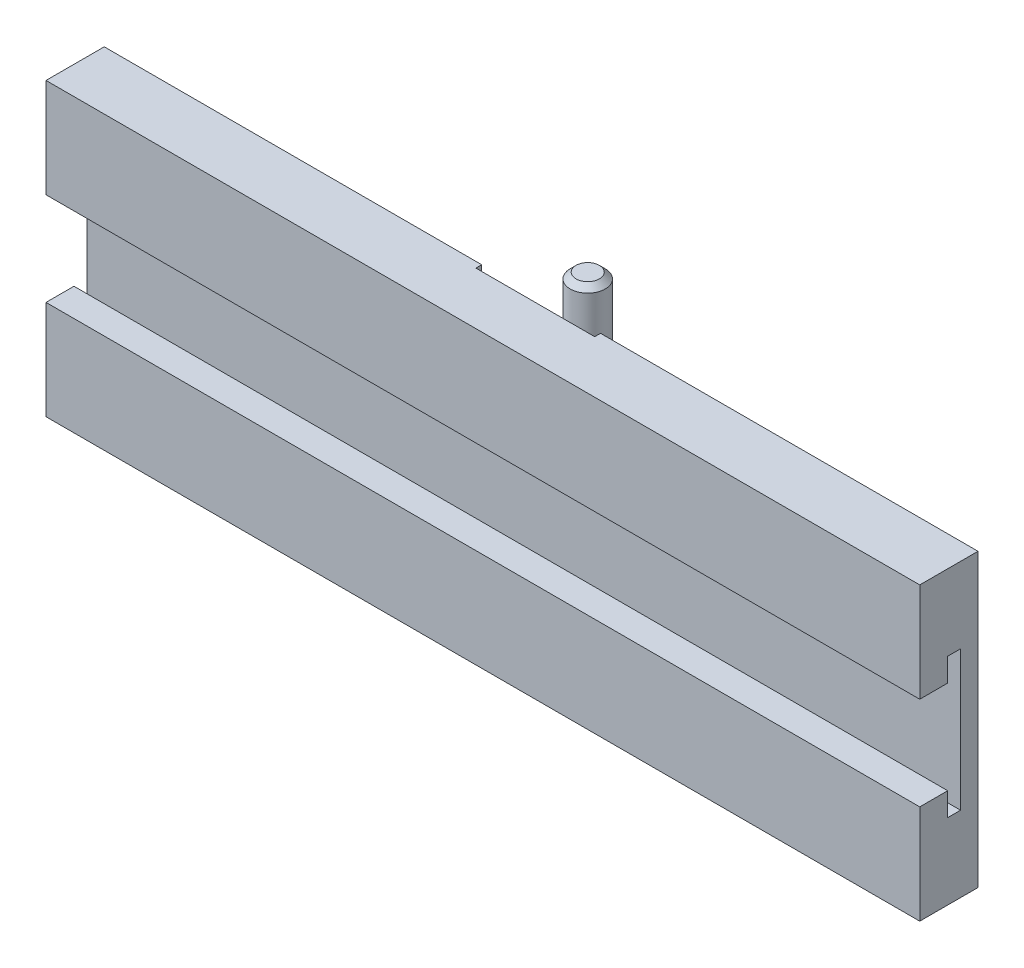
from build123d import *

# Parameters (mm, degrees)
SKETCH_1_W          = 150
SKETCH_1_H          = 50
EXTRUDE_1_DEPTH     = 10
CUT_EXTRUDE_1_DEPTH = 150
SKETCH_3_W          = 20.4
SKETCH_3_H          = 1
CUT_EXTRUDE_2_DEPTH = 150
SKETCH_4_W          = 20.4
SKETCH_4_H          = 5
EXTRUDE_2_DEPTH     = 12
SKETCH_5_R          = 3.01
EXTRUDE_3_DEPTH     = 45
CHAMFER_2_SIZE      = 1


with BuildPart() as part:
    # 草图1 → 凸台-拉伸1 (new body)
    with BuildSketch(Plane.XY):
        with Locations((50.269431659, 25)):
            Rectangle(SKETCH_1_W, SKETCH_1_H)
    extrude(amount=EXTRUDE_1_DEPTH)

    # 草图2 → 切除-拉伸1 (cut)
    with BuildSketch(Plane(origin=(125.269431659, 0, 0), x_dir=(0, 0, -1), z_dir=(1, 0, 0))):
        Polygon((-3, 13), (-3, 37), (-5.2, 37), (-5.2, 33), (-10, 33), (-10, 17), (-5.2, 17), (-5.2, 13), align=None)
    extrude(amount=-CUT_EXTRUDE_1_DEPTH, mode=Mode.SUBTRACT)

    # 草图3 → 切除-拉伸2 (cut)
    with BuildSketch(Plane(origin=(0, 50, 0), x_dir=(1, 0, 0), z_dir=(0, 1, 0))):
        with Locations((50.269431659, -0.5)):
            Rectangle(SKETCH_3_W, SKETCH_3_H)
    extrude(amount=-CUT_EXTRUDE_2_DEPTH, mode=Mode.SUBTRACT)

    # 草图4 → 凸台-拉伸2 (add)
    with BuildSketch(Plane(origin=(0, 0, 1), x_dir=(-1, 0, 0), z_dir=(0, 0, -1))):
        with Locations((-50.269431659, 2.5)):
            Rectangle(SKETCH_4_W, SKETCH_4_H)
    extrude(amount=EXTRUDE_2_DEPTH)

    # 草图5 → 凸台-拉伸3 (add)
    with BuildSketch(Plane(origin=(0, 5, 0), x_dir=(1, 0, 0), z_dir=(0, 1, 0))):
        with Locations((50.269431659, 8)):
            Circle(SKETCH_5_R)
    extrude(amount=EXTRUDE_3_DEPTH)

    # 倒角2
    chamfer_2_edges = [part.edges().sort_by_distance(p)[0] for p in [
        (47.259431659, 50, -8),
    ]]
    chamfer(chamfer_2_edges, length=CHAMFER_2_SIZE)


solid = part.part
